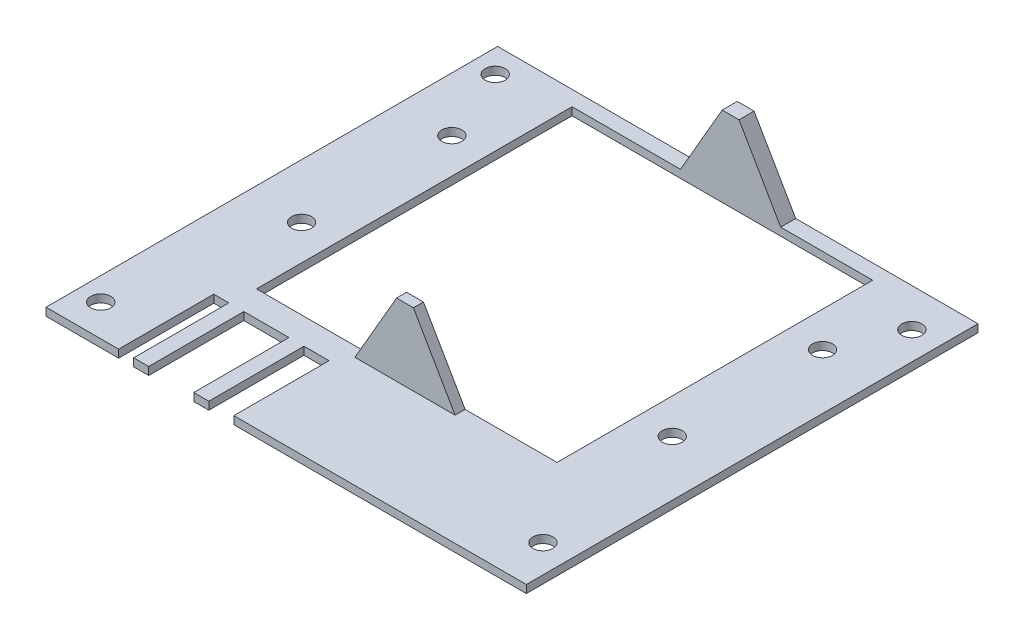
from build123d import *

# Parameters (mm, degrees)
SKETCH1_W               = 96.89
SKETCH1_H               = 90.17
PCB_DEPTH               = 1.57
SKETCH2_R               = 2
M3_MOUNTING_HOLES_DEPTH = 1.57
SKETCH4_R               = 2
CUT_EXTRUDE1_DEPTH      = 23
BOSS_EXTRUDE2_DEPTH     = 2
BOSS_EXTRUDE3_DEPTH     = 3
SKETCH9_W               = 3
SKETCH9_H               = 19
SKETCH9_W_2             = 9
SKETCH9_W_3             = 5
CUT_EXTRUDE2_DEPTH      = 2.57
SKETCH10_W              = 0.5
SKETCH10_H              = 90.17
CUT_EXTRUDE3_DEPTH      = 10
SKETCH11_W              = 60
SKETCH11_H              = 63
CUT_EXTRUDE4_DEPTH      = 10


with BuildPart() as part:
    # Sketch1 → PCB (new body)
    with BuildSketch(Plane(origin=(0, 0, 0), x_dir=(1, 0, 0), z_dir=(0, 1, 0))):
        with Locations((16.200949951, 63.633996534)):
            Rectangle(SKETCH1_W, SKETCH1_H)
    extrude(amount=PCB_DEPTH)

    # Sketch2 → M3 Mounting Holes (cut)
    with BuildSketch(Plane(origin=(0, 1.57, 0), x_dir=(1, 0, 0), z_dir=(0, 1, 0))):
        with Locations((58.565949951, 27.438996534)):
            Circle(SKETCH2_R)
        with Locations((-27.164050049, 24.898996534)):
            Circle(SKETCH2_R)
        with Locations((-27.164050049, 103.638996534)):
            Circle(SKETCH2_R)
        with Locations((58.565949951, 101.098996534)):
            Circle(SKETCH2_R)
    extrude(amount=-M3_MOUNTING_HOLES_DEPTH, mode=Mode.SUBTRACT)

    # Sketch4 → Cut-Extrude1 (cut)
    with BuildSketch(Plane(origin=(0, 1.57, 0), x_dir=(1, 0, 0), z_dir=(0, 1, 0))):
        with Locations((-20.894050049, 88.718996534)):
            Circle(SKETCH4_R)
        with Locations((53.105949951, 88.718996534)):
            Circle(SKETCH4_R)
        with Locations((-20.894050049, 58.718996534)):
            Circle(SKETCH4_R)
        with Locations((53.105949951, 58.718996534)):
            Circle(SKETCH4_R)
    extrude(amount=-CUT_EXTRUDE1_DEPTH, mode=Mode.SUBTRACT)

    # Sketch7 → Boss-Extrude2 (add)
    with BuildSketch(Plane.XY.offset(-42.718996534)):
        Polygon((27.755949951, 1.57), (19.438412086, 15.976398176), (16.073487816, 15.976398176), (7.755949951, 1.57), align=None)
    extrude(amount=BOSS_EXTRUDE2_DEPTH)

    # Sketch8 → Boss-Extrude3 (add)
    with BuildSketch(Plane.XY.offset(-108.718996534)):
        Polygon((27.755949951, 1.57), (19.438412086, 15.976398176), (16.073487816, 15.976398176), (7.755949951, 1.57), align=None)
    extrude(amount=BOSS_EXTRUDE3_DEPTH)

    # Sketch9 → Cut-Extrude2 (cut, through all)
    with BuildSketch(Plane(origin=(0, 1.57, 0), x_dir=(1, 0, 0), z_dir=(0, 1, 0))):
        with Locations((-15.744050049, 28.048996534)):
            Rectangle(SKETCH9_W, SKETCH9_H)
        with Locations((-6.744050049, 28.048996534)):
            Rectangle(SKETCH9_W_2, SKETCH9_H)
        with Locations((3.255949951, 28.048996534)):
            Rectangle(SKETCH9_W_3, SKETCH9_H)
    extrude(amount=-CUT_EXTRUDE2_DEPTH, mode=Mode.SUBTRACT)

    # Sketch10 → Cut-Extrude3 (cut)
    with BuildSketch(Plane(origin=(0, 1.57, 0), x_dir=(1, 0, 0), z_dir=(0, 1, 0))):
        with Locations((-31.994050049, 63.633996534)):
            Rectangle(SKETCH10_W, SKETCH10_H)
        with Locations((64.395949951, 63.633996534)):
            Rectangle(SKETCH10_W, SKETCH10_H)
    extrude(amount=-CUT_EXTRUDE3_DEPTH, mode=Mode.SUBTRACT)

    # Sketch11 → Cut-Extrude4 (cut)
    with BuildSketch(Plane(origin=(0, 1.57, 0), x_dir=(1, 0, 0), z_dir=(0, 1, 0))):
        with Locations((16.105949951, 74.218996534)):
            Rectangle(SKETCH11_W, SKETCH11_H)
    extrude(amount=-CUT_EXTRUDE4_DEPTH, mode=Mode.SUBTRACT)


solid = part.part
